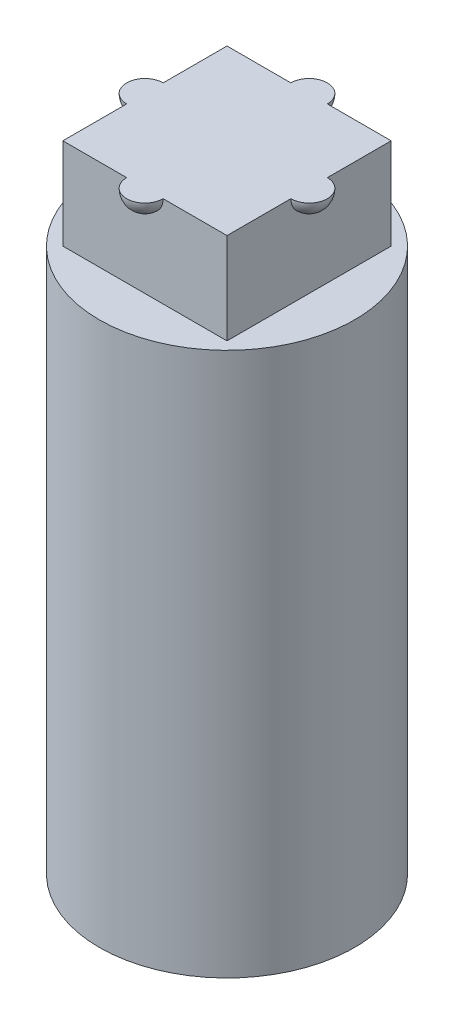
from build123d import *

# Parameters (mm, degrees)
SKETCH_1_R          = 3.5
EXTRUDE_1_DEPTH     = 4
SKETCH_2_R          = 3.5
EXTRUDE_2_DEPTH     = 10.9
SKETCH_3_W          = 4.5
SKETCH_3_H          = 4.5
EXTRUDE_3_DEPTH     = 2.5
SKETCH_6_R          = 3.25
CUT_EXTRUDE_1_DEPTH = 2.5


with BuildPart() as part:
    # 草图1 → 凸台-拉伸1 (new body)
    with BuildSketch(Plane(origin=(0, 0, 0), x_dir=(1, 0, 0), z_dir=(0, 1, 0))):
        Circle(SKETCH_1_R)
        with BuildLine():
            Line((-0.95, 1.2), (0.95, 1.2))
            ThreePointArc((0.95, 1.2), (1.376776695, 1.376776695), (1.2, 0.95))
            Line((1.2, 0.95), (1.2, -0.95))
            ThreePointArc((1.2, -0.95), (1.376776695, -1.376776695), (0.95, -1.2))
            Line((0.95, -1.2), (-0.95, -1.2))
            ThreePointArc((-0.95, -1.2), (-1.376776695, -1.376776695), (-1.2, -0.95))
            Line((-1.2, -0.95), (-1.2, 0.95))
            ThreePointArc((-1.2, 0.95), (-1.376776695, 1.376776695), (-0.95, 1.2))
        make_face(mode=Mode.SUBTRACT)
    extrude(amount=EXTRUDE_1_DEPTH)

    # 草图2 → 凸台-拉伸2 (add)
    with BuildSketch(Plane(origin=(0, 4, 0), x_dir=(1, 0, 0), z_dir=(0, 1, 0))):
        Circle(SKETCH_2_R)
    extrude(amount=EXTRUDE_2_DEPTH)

    # 草图3 → 凸台-拉伸3 (add)
    with BuildSketch(Plane(origin=(0, 14.9, 0), x_dir=(1, 0, 0), z_dir=(0, 1, 0))):
        Rectangle(SKETCH_3_W, SKETCH_3_H)
    extrude(amount=EXTRUDE_3_DEPTH)

    # 草图4 → 旋转1 (revolve)
    with BuildSketch(Plane(origin=(0, 17.4, 0), x_dir=(1, 0, 0), z_dir=(0, 1, 0))):
        with BuildLine():
            Line((0, 2.75), (0, 1.75))
            ThreePointArc((0, 1.75), (-0.5, 2.25), (0, 2.75))
        make_face()
        with BuildLine():
            Line((0, -1.75), (0, -2.75))
            ThreePointArc((0, -2.75), (-0.5, -2.25), (0, -1.75))
        make_face()
    revolve(axis=Axis((0, 17.4, -2.75), (0, 0, 1)))

    # 草图5 → 旋转2 (revolve)
    with BuildSketch(Plane(origin=(0, 17.4, 0), x_dir=(1, 0, 0), z_dir=(0, 1, 0))):
        with BuildLine():
            Line((-2.75, 0), (-1.75, 0))
            ThreePointArc((-1.75, 0), (-2.25, 0.5), (-2.75, 0))
        make_face()
        with BuildLine():
            Line((1.75, 0), (2.75, 0))
            ThreePointArc((2.75, 0), (2.25, 0.5), (1.75, 0))
        make_face()
    revolve(axis=Axis((-2.75, 17.4, 0), (1, 0, 0)))

    # 草图6 → 切除-拉伸1 (cut)
    with BuildSketch(Plane(origin=(0, 17.4, 0), x_dir=(1, 0, 0), z_dir=(0, 1, 0))):
        Circle(SKETCH_6_R)
    extrude(amount=CUT_EXTRUDE_1_DEPTH, mode=Mode.SUBTRACT)


solid = part.part
